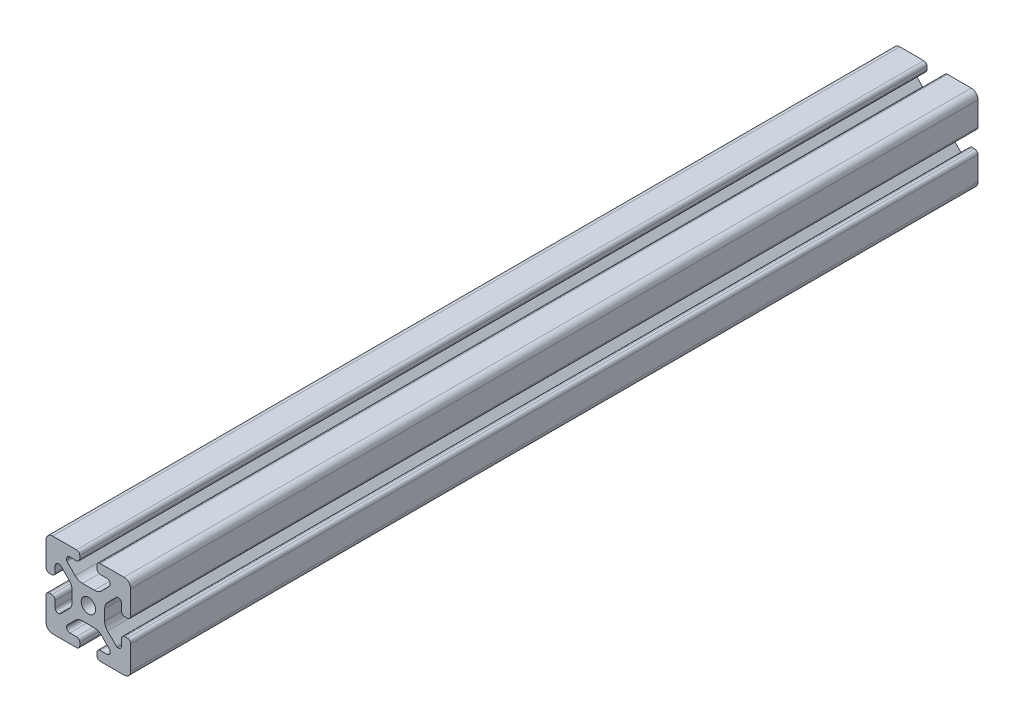
from build123d import *

# Parameters (mm, degrees)
SKETCH1_R      = 3.4
EXTRUDE1_DEPTH = 400


with BuildPart() as part:
    # Sketch1 → Extrude1 (new body)
    with BuildSketch(Plane.XY):
        with BuildLine():
            Line((-8.715, -15.524615034), (-5.63, -15.524615034))
            ThreePointArc((-5.63, -15.524615034), (-4.519842354, -15.984457388), (-4.06, -17.094615034))
            Line((-4.06, -17.094615034), (-4.06, -18.43))
            ThreePointArc((-4.06, -18.43), (-4.519842354, -19.540157646), (-5.63, -20))
            Line((-5.63, -20), (-16.674615034, -20))
            ThreePointArc((-16.674615034, -20), (-18.951578385, -19.194274381), (-20, -17.018368134))
            Line((-20, -17.018368134), (-20, -5.757918808))
            ThreePointArc((-20, -5.757918808), (-19.564709668, -4.603883664), (-18.43, -4.120449326))
            Line((-18.43, -4.120449326), (-17.25, -4.120449326))
            ThreePointArc((-17.25, -4.120449326), (-16.115287682, -4.60388249), (-15.67999625, -5.757919334))
            Line((-15.67999625, -5.757919334), (-15.67999625, -8.715399492))
            ThreePointArc((-15.67999625, -8.715399492), (-15.220153896, -9.825557139), (-14.10999625, -10.285399492))
            Line((-14.10999625, -10.285399492), (-13.816898819, -10.285399492))
            ThreePointArc((-13.816898819, -10.285399492), (-13.526061711, -10.227547119), (-13.279501941, -10.062800646))
            Line((-13.279501941, -10.062800646), (-9.076242789, -5.859541495))
            ThreePointArc((-9.076242789, -5.859541495), (-8.046572221, -4.318530588), (-7.685, -2.500784284))
            Line((-7.685, -2.500784284), (-7.685, 2.500784284))
            ThreePointArc((-7.685, 2.500784284), (-8.046572221, 4.318530588), (-9.076242789, 5.859541495))
            Line((-9.076242789, 5.859541495), (-13.040489136, 9.823787841))
            ThreePointArc((-13.040489136, 9.823787841), (-13.354224618, 10.012729352), (-13.71989919, 10.033001362))
            Line((-13.71989919, 10.033001362), (-14.05520779, 10.044710596))
            ThreePointArc((-14.05520779, 10.044710596), (-15.200613642, 9.605030484), (-15.68, 8.475666998))
            Line((-15.68, 8.475666998), (-15.68, 5.572979049))
            ThreePointArc((-15.68, 5.572979049), (-16.139842354, 4.462821403), (-17.25, 4.002979049))
            Line((-17.25, 4.002979049), (-18.43, 4.002979049))
            ThreePointArc((-18.43, 4.002979049), (-19.540157646, 4.462821403), (-20, 5.572979049))
            Line((-20, 5.572979049), (-20, 13.004526564))
            Line((-20, 13.004526564), (-20, 16.83))
            ThreePointArc((-20, 16.83), (-19.071528496, 19.071528496), (-16.83, 20))
            Line((-16.83, 20), (-5.63, 20))
            ThreePointArc((-5.63, 20), (-4.519842354, 19.540157646), (-4.06, 18.43))
            Line((-4.06, 18.43), (-4.06, 17.094615034))
            ThreePointArc((-4.06, 17.094615034), (-4.519842354, 15.984457388), (-5.63, 15.524615034))
            Line((-5.63, 15.524615034), (-8.715, 15.524615034))
            ThreePointArc((-8.715, 15.524615034), (-9.825157646, 15.06477268), (-10.285, 13.954615034))
            Line((-10.285, 13.954615034), (-10.285, 13.492503602))
            ThreePointArc((-10.285, 13.492503602), (-10.227148445, 13.201664194), (-10.062401154, 12.955102448))
            Line((-10.062401154, 12.955102448), (-6.217092793, 9.109794088))
            ThreePointArc((-6.217092793, 9.109794088), (-4.63891877, 8.055291919), (-2.777335583, 7.685))
            Line((-2.777335583, 7.685), (2.777335583, 7.685))
            ThreePointArc((2.777335583, 7.685), (4.63891877, 8.055291919), (6.217092793, 9.109794088))
            Line((6.217092793, 9.109794088), (10.062401154, 12.955102448))
            ThreePointArc((10.062401154, 12.955102448), (10.227148445, 13.201664194), (10.285, 13.492503602))
            Line((10.285, 13.492503602), (10.285, 13.954615034))
            ThreePointArc((10.285, 13.954615034), (9.825157646, 15.06477268), (8.715, 15.524615034))
            Line((8.715, 15.524615034), (5.63, 15.524615034))
            ThreePointArc((5.63, 15.524615034), (4.519842354, 15.984457388), (4.06, 17.094615034))
            Line((4.06, 17.094615034), (4.06, 18.43))
            ThreePointArc((4.06, 18.43), (4.519842354, 19.540157646), (5.63, 20))
            Line((5.63, 20), (12.979635074, 20))
            Line((12.979635074, 20), (16.83, 20))
            ThreePointArc((16.83, 20), (19.071528496, 19.071528496), (20, 16.83))
            Line((20, 16.83), (20, 13.001098436))
            Line((20, 13.001098436), (20, 5.63))
            ThreePointArc((20, 5.63), (19.540157461, 4.519842693), (18.43, 4.060000526))
            Line((18.43, 4.060000526), (17.24999625, 4.060000526))
            ThreePointArc((17.24999625, 4.060000526), (16.139838603, 4.519842879), (15.67999625, 5.630000526))
            Line((15.67999625, 5.630000526), (15.67999625, 8.715399492))
            ThreePointArc((15.67999625, 8.715399492), (15.220153896, 9.825557139), (14.10999625, 10.285399492))
            Line((14.10999625, 10.285399492), (13.816903094, 10.285399492))
            ThreePointArc((13.816903094, 10.285399492), (13.526063686, 10.227547937), (13.279501941, 10.062800646))
            Line((13.279501941, 10.062800646), (9.076242789, 5.859541495))
            ThreePointArc((9.076242789, 5.859541495), (8.046572221, 4.318530588), (7.685, 2.500784284))
            Line((7.685, 2.500784284), (7.685, -2.500784284))
            ThreePointArc((7.685, -2.500784284), (8.046572221, -4.318530588), (9.076242789, -5.859541495))
            Line((9.076242789, -5.859541495), (13.163657296, -9.946956002))
            ThreePointArc((13.163657296, -9.946956002), (13.35903797, -10.160433474), (13.6200547, -10.285399492))
            Line((13.6200547, -10.285399492), (14.10999625, -10.285399492))
            ThreePointArc((14.10999625, -10.285399492), (15.220153896, -9.825557139), (15.67999625, -8.715399492))
            Line((15.67999625, -8.715399492), (15.67999625, -5.630000526))
            ThreePointArc((15.67999625, -5.630000526), (16.139838603, -4.519842879), (17.24999625, -4.060000526))
            Line((17.24999625, -4.060000526), (18.43, -4.060000526))
            ThreePointArc((18.43, -4.060000526), (19.540157461, -4.519842693), (20, -5.63))
            Line((20, -5.63), (20, -16.83))
            ThreePointArc((20, -16.83), (19.071528496, -19.071528496), (16.83, -20))
            Line((16.83, -20), (13, -20))
            Line((13, -20), (5.63, -20))
            ThreePointArc((5.63, -20), (4.519842354, -19.540157646), (4.06, -18.43))
            Line((4.06, -18.43), (4.06, -17.094615034))
            ThreePointArc((4.06, -17.094615034), (4.519842354, -15.984457388), (5.63, -15.524615034))
            Line((5.63, -15.524615034), (8.715, -15.524615034))
            ThreePointArc((8.715, -15.524615034), (9.825157646, -15.06477268), (10.285, -13.954615034))
            Line((10.285, -13.954615034), (10.285, -13.492503602))
            ThreePointArc((10.285, -13.492503602), (10.227148445, -13.201664194), (10.062401154, -12.955102448))
            Line((10.062401154, -12.955102448), (6.217092793, -9.109794088))
            ThreePointArc((6.217092793, -9.109794088), (4.63891877, -8.055291919), (2.777335583, -7.685))
            Line((2.777335583, -7.685), (-2.777335583, -7.685))
            ThreePointArc((-2.777335583, -7.685), (-4.63891877, -8.055291919), (-6.217092793, -9.109794088))
            Line((-6.217092793, -9.109794088), (-10.062401154, -12.955102448))
            ThreePointArc((-10.062401154, -12.955102448), (-10.227148445, -13.201664194), (-10.285, -13.492503602))
            Line((-10.285, -13.492503602), (-10.285, -13.954615034))
            ThreePointArc((-10.285, -13.954615034), (-9.825157646, -15.06477268), (-8.715, -15.524615034))
        make_face()
        Circle(SKETCH1_R, mode=Mode.SUBTRACT)
    extrude(amount=-EXTRUDE1_DEPTH)


solid = part.part
